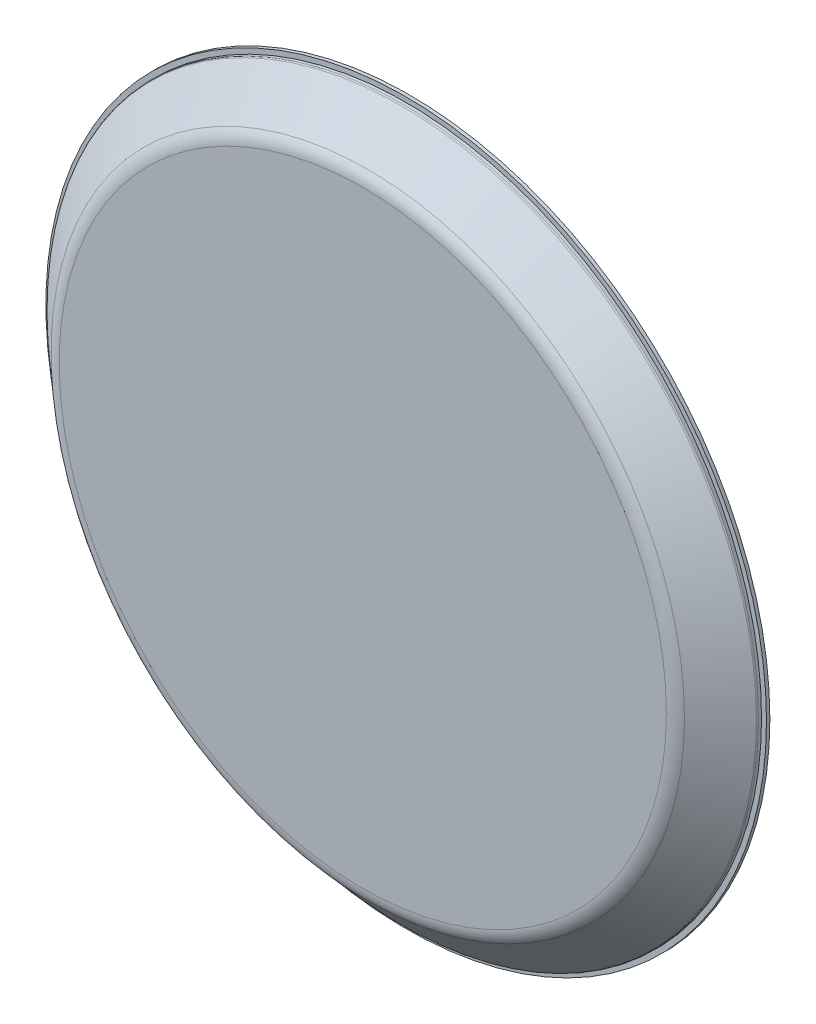
from build123d import *


with BuildPart() as part:
    # Sketch1 → Revolve1 (revolve)
    with BuildSketch(Plane(origin=(0, 0, 0), x_dir=(0, 0, -1), z_dir=(1, 0, 0))):
        with BuildLine():
            Line((0.199998156, 18.250858843), (0.368480901, 18.253649875))
            Line((0.368480901, 18.253649875), (0.368480901, 17.564198472))
            ThreePointArc((0.368480901, 17.564198472), (0.36191796, 17.528568202), (0.34309058, 17.497614721))
            Line((0.34309058, 17.497614721), (-1.298438714, 15.6582174))
            ThreePointArc((-1.298438714, 15.6582174), (-1.373748235, 15.534403473), (-1.4, 15.391882396))
            Line((-1.4, 15.391882396), (-1.4, 0))
            Line((-1.4, 0), (-2, 0))
            Line((-2, 0), (-2, 15.377593236))
            ThreePointArc((-2, 15.377593236), (-1.934370586, 15.733895926), (-1.746096785, 16.043430744))
            Line((-1.746096785, 16.043430744), (-0.029650113, 17.966775897))
            ThreePointArc((-0.029650113, 17.966775897), (0.003888132, 17.991368554), (0.044530144, 18.000191224))
            Line((0.044530144, 18.000191224), (0.199998156, 18.000858843))
            Line((0.199998156, 18.000858843), (0.199998156, 18.250858843))
        make_face()
    revolve(axis=Axis((0, 0, 10.644061054), (0, 0, -1)))


solid = part.part
